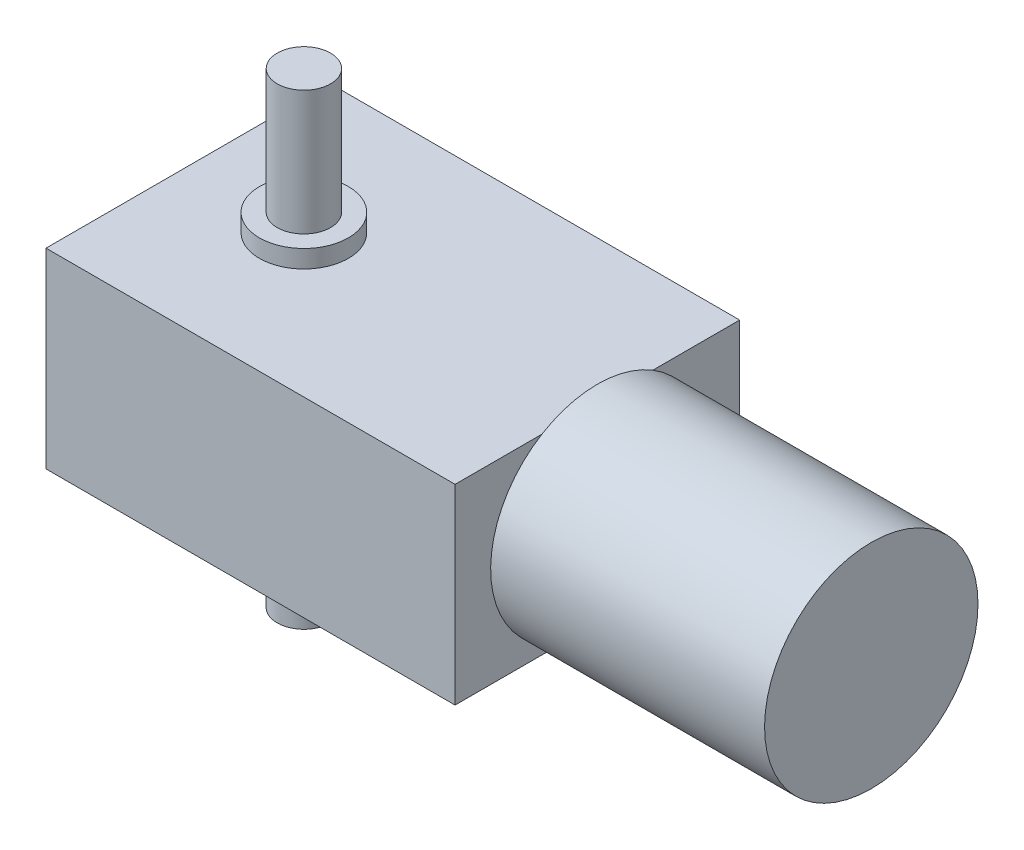
from build123d import *

# Parameters (mm, degrees)
SKETCH_2_W      = 46
SKETCH_2_H      = 21.5
EXTRUDE_1_DEPTH = 32
SKETCH_3_R      = 5
EXTRUDE_2_DEPTH = 2
SKETCH_4_R      = 3
EXTRUDE_3_DEPTH = 14
SKETCH_5_R      = 12
EXTRUDE_4_DEPTH = 30.8


with BuildPart() as part:
    # 草图2 → 凸台-拉伸1 (new body)
    with BuildSketch(Plane.XY):
        with Locations((2.647117171, 17.006037157)):
            Rectangle(SKETCH_2_W, SKETCH_2_H)
    extrude(amount=EXTRUDE_1_DEPTH)

    # 草图3 → 凸台-拉伸2 (add)
    with BuildSketch(Plane(origin=(0, 27.756037157, 0), x_dir=(1, 0, 0), z_dir=(0, 1, 0))):
        with Locations((-7.352882829, -16)):
            Circle(SKETCH_3_R)
    extrude_2 = extrude(amount=EXTRUDE_2_DEPTH)

    # 草图4 → 凸台-拉伸3 (add)
    with BuildSketch(Plane(origin=(0, 29.756037157, 0), x_dir=(1, 0, 0), z_dir=(0, 1, 0))):
        with Locations((-7.352882829, -16)):
            Circle(SKETCH_4_R)
    extrude_3 = extrude(amount=EXTRUDE_3_DEPTH)

    # 镜向1: 凸台-拉伸2, 凸台-拉伸3 across plane
    add(extrude_2.mirror(Plane.ZX.offset(17.506037157)))
    add(extrude_3.mirror(Plane.ZX.offset(17.506037157)))

    # 草图5 → 凸台-拉伸4 (add)
    with BuildSketch(Plane(origin=(25.647117171, 0, 0), x_dir=(0, 0, -1), z_dir=(1, 0, 0))):
        with Locations((-16, 17.506037157)):
            Circle(SKETCH_5_R)
    extrude(amount=EXTRUDE_4_DEPTH)


solid = part.part
